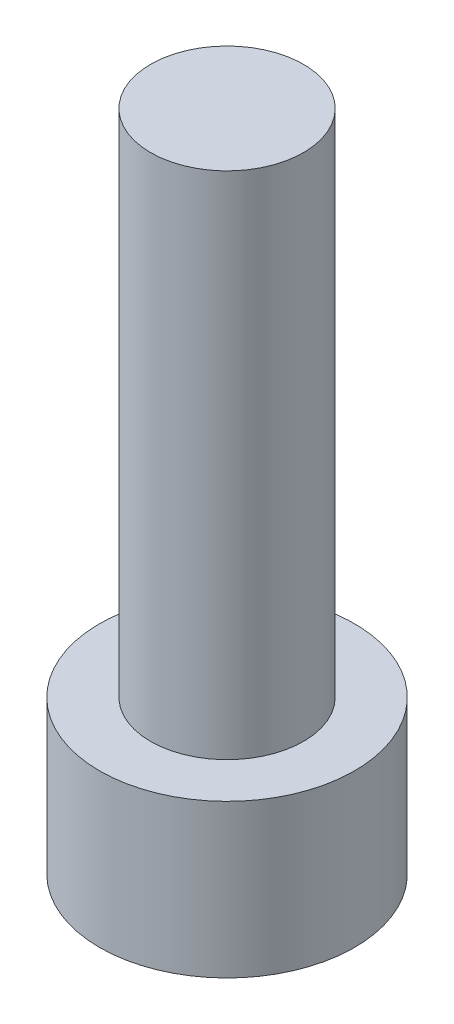
from build123d import *

# Parameters (mm, degrees)
SKETCH_1_R          = 2.5
EXTRUDE_1_DEPTH     = 3
SKETCH_2_R          = 1.5
EXTRUDE_2_DEPTH     = 10
CUT_EXTRUDE_1_DEPTH = 1.65


with BuildPart() as part:
    # 草图1 → 凸台-拉伸1 (new body)
    with BuildSketch(Plane(origin=(0, 0, 0), x_dir=(1, 0, 0), z_dir=(0, 1, 0))):
        Circle(SKETCH_1_R)
    extrude(amount=EXTRUDE_1_DEPTH)

    # 草图2 → 凸台-拉伸2 (add)
    with BuildSketch(Plane(origin=(0, 3, 0), x_dir=(1, 0, 0), z_dir=(0, 1, 0))):
        Circle(SKETCH_2_R)
    extrude(amount=EXTRUDE_2_DEPTH)

    # 草图3 → 切除-拉伸1 (cut)
    with BuildSketch(Plane.XZ):
        Polygon((1.425, 0), (0.7125, 1.2340862), (-0.7125, 1.2340862), (-1.425, 0), (-0.7125, -1.2340862), (0.7125, -1.2340862), align=None)
    extrude(amount=-CUT_EXTRUDE_1_DEPTH, mode=Mode.SUBTRACT)


solid = part.part
